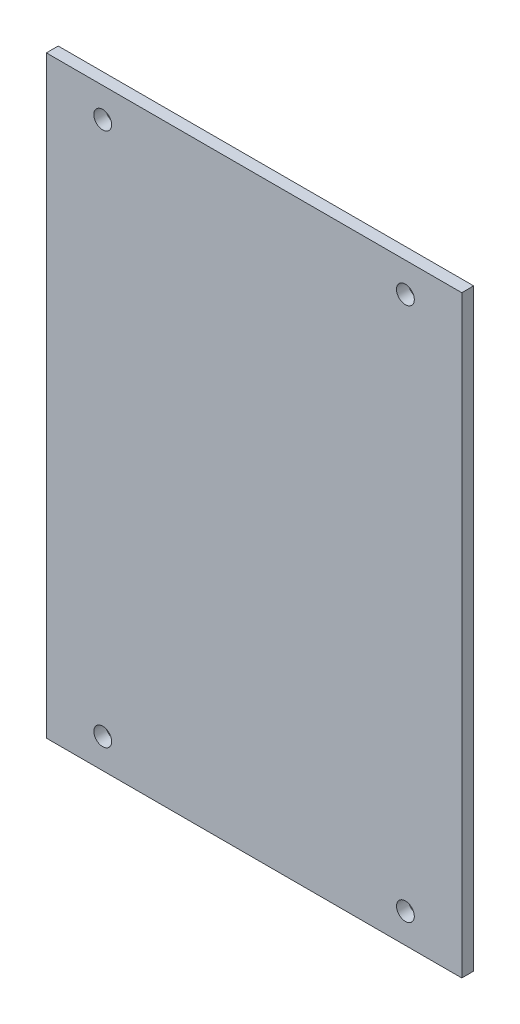
from build123d import *

# Parameters (mm, degrees)
SKETCH1_R           = 1
BOSS_EXTRUDE1_DEPTH = 5
SKETCH3_W           = 51
SKETCH3_H           = 56
BOSS_EXTRUDE3_DEPTH = 2
SKETCH7_W           = 70
SKETCH7_H           = 100
SKETCH7_R           = 1.5
BOSS_EXTRUDE5_DEPTH = 2


with BuildPart() as part:
    # Sketch1 → Boss-Extrude1 (new body)
    with BuildSketch(Plane.XY):
        Polygon((-25.5, -13), (25.5, -13), (25.5, 13), (25.5, 17), (25.5, 43), (-25.5, 43), (-25.5, 17), (-25.5, 13), align=None)
        with Locations((-23.500000003, 11.000000003)):
            Circle(SKETCH1_R, mode=Mode.SUBTRACT)
        with Locations((-23.500000003, -11.000000003)):
            Circle(SKETCH1_R, mode=Mode.SUBTRACT)
        with Locations((23.500000003, -11.000000003)):
            Circle(SKETCH1_R, mode=Mode.SUBTRACT)
        with Locations((23.500000003, 11.000000003)):
            Circle(SKETCH1_R, mode=Mode.SUBTRACT)
        with Locations((23.500000003, 18.999999997)):
            Circle(SKETCH1_R, mode=Mode.SUBTRACT)
        with Locations((23.500000003, 41.000000003)):
            Circle(SKETCH1_R, mode=Mode.SUBTRACT)
        with Locations((-23.500000003, 41.000000003)):
            Circle(SKETCH1_R, mode=Mode.SUBTRACT)
        with Locations((-23.500000003, 18.999999997)):
            Circle(SKETCH1_R, mode=Mode.SUBTRACT)
    extrude(amount=BOSS_EXTRUDE1_DEPTH)

    # Sketch3 → Boss-Extrude3 (add)
    with BuildSketch(Plane.XY.offset(5)):
        with Locations((0, 15)):
            Rectangle(SKETCH3_W, SKETCH3_H)
    extrude(amount=BOSS_EXTRUDE3_DEPTH)

    # Sketch7 → Boss-Extrude5 (add)
    with BuildSketch(Plane.XY.offset(7)):
        with Locations((0, 15)):
            Rectangle(SKETCH7_W, SKETCH7_H)
        with Locations((-25.5, -30)):
            Circle(SKETCH7_R, mode=Mode.SUBTRACT)
        with Locations((25.5, -30)):
            Circle(SKETCH7_R, mode=Mode.SUBTRACT)
        with Locations((25.5, 60)):
            Circle(SKETCH7_R, mode=Mode.SUBTRACT)
        with Locations((-25.5, 60)):
            Circle(SKETCH7_R, mode=Mode.SUBTRACT)
    extrude(amount=BOSS_EXTRUDE5_DEPTH)


solid = part.part
